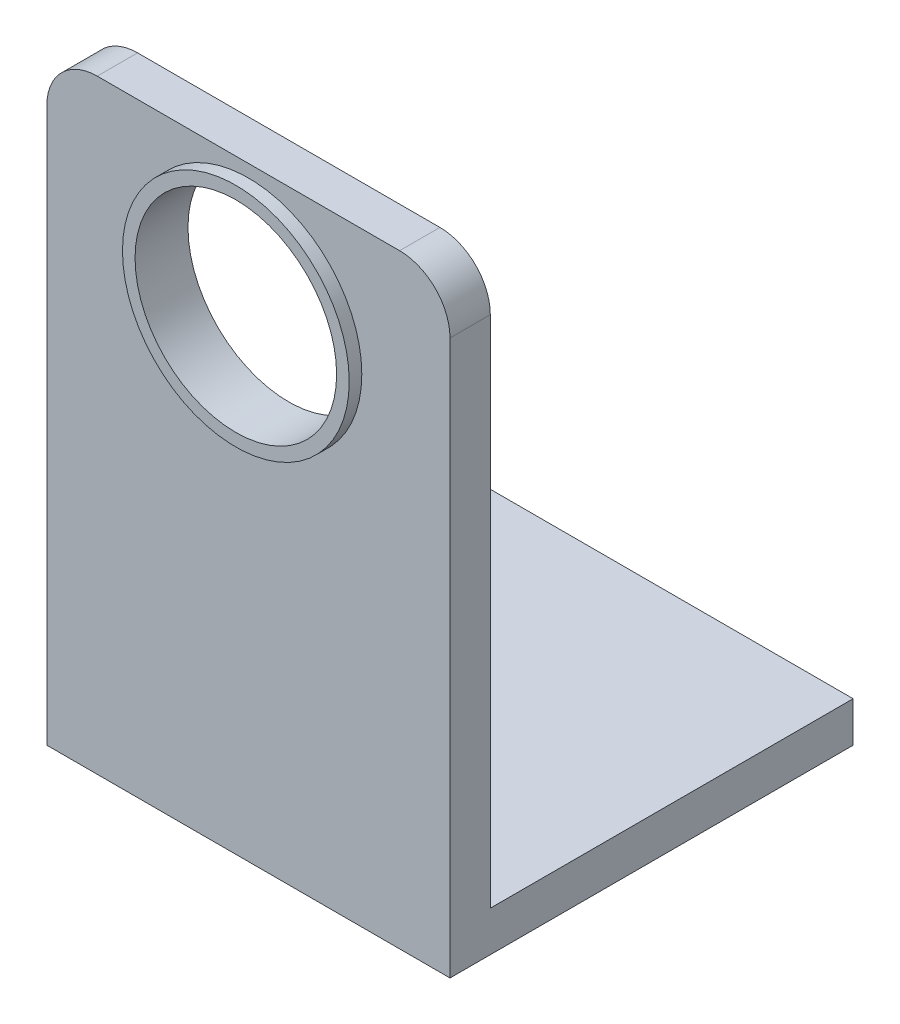
from build123d import *

# Parameters (mm, degrees)
BOSS_EXTRUDE1_DEPTH = 25.4
CUT_EXTRUDE1_REACH  = 53.18
SKETCH2_R           = 6.35
FILLET1_R           = 3.175
SKETCH3_R           = 7.14375
SKETCH3_R_2         = 6.35
BOSS_EXTRUDE2_DEPTH = 0.79375


with BuildPart() as part:
    # Sketch1 → Boss-Extrude1 (new body)
    with BuildSketch(Plane(origin=(0, 0, 0), x_dir=(0, 0, -1), z_dir=(1, 0, 0))):
        Polygon((2.54, 2.54), (25.4, 2.54), (25.4, 0), (0, 0), (0, 38.1), (2.54, 38.1), align=None)
    extrude(amount=BOSS_EXTRUDE1_DEPTH)

    # Sketch2 → Cut-Extrude1 (cut, up to next)
    with BuildSketch(Plane(origin=(0, 0, -2.54), x_dir=(-1, 0, 0), z_dir=(0, 0, -1)), mode=Mode.PRIVATE) as cut_extrude1_sk1:
        with Locations((-12.7, 30.1625)):
            Circle(SKETCH2_R)
    cut_extrude1_tool1 = extrude(cut_extrude1_sk1.sketch, amount=-CUT_EXTRUDE1_REACH, mode=Mode.PRIVATE) & part.part
    add(cut_extrude1_tool1.solids().sort_by_distance((12.7, 30.1625, -2.54))[0], mode=Mode.SUBTRACT)

    # Fillet1
    fillet1_edges = [part.edges().sort_by_distance(p)[0] for p in [
        (25.4, 38.1, -1.27),
        (0, 38.1, -1.27),
    ]]
    fillet(fillet1_edges, radius=FILLET1_R)

    # Sketch3 → Boss-Extrude2 (add)
    with BuildSketch(Plane.XY):
        with Locations(Location((12.7, 30.1625, 0), (0, 0, 180))):
            Circle(SKETCH3_R)
        with Locations(Location((12.7, 30.1625, 0), (0, 0, 180))):
            Circle(SKETCH3_R_2, mode=Mode.SUBTRACT)
    extrude(amount=BOSS_EXTRUDE2_DEPTH)


solid = part.part
